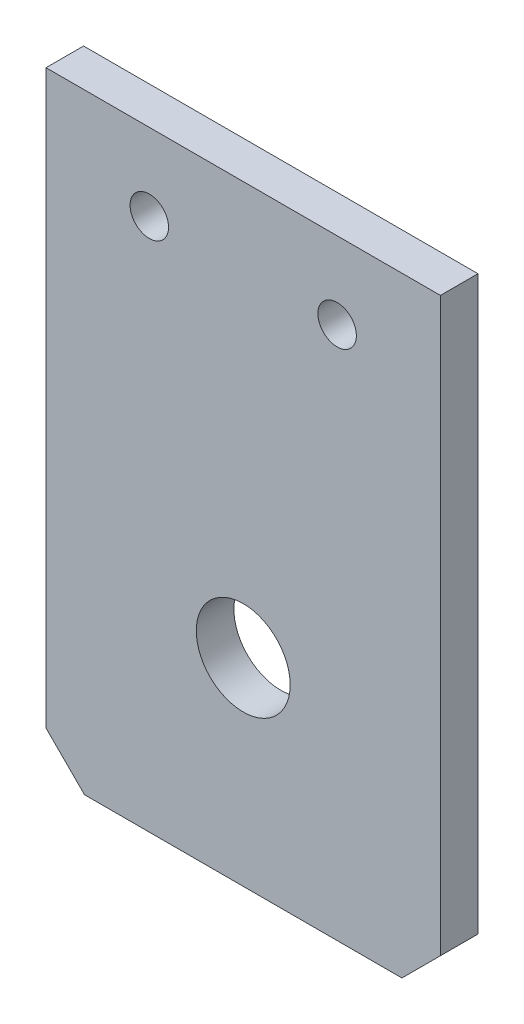
from build123d import *

# Parameters (mm, degrees)
CROQUIS1_W              = 42
CROQUIS1_H              = 65
CROQUIS1_R              = 2.05
SALIENTE_EXTRUIR1_DEPTH = 4
CHAFL_N1_SIZE           = 4.1
CROQUIS5_R              = 5
CORTAR_EXTRUIR2_DEPTH   = 5


with BuildPart() as part:
    # Croquis1 → Saliente-Extruir1 (new body)
    with BuildSketch(Plane.XY):
        with Locations((21, 32.5)):
            Rectangle(CROQUIS1_W, CROQUIS1_H)
        with Locations((11, 56.8)):
            Circle(CROQUIS1_R, mode=Mode.SUBTRACT)
        with Locations((31, 56.8)):
            Circle(CROQUIS1_R, mode=Mode.SUBTRACT)
    extrude(amount=SALIENTE_EXTRUIR1_DEPTH)

    # Chaflán1
    chafl_n1_edges = [part.edges().sort_by_distance(p)[0] for p in [
        (42, 0, 2),
        (0, 0, 2),
    ]]
    chamfer(chafl_n1_edges, length=CHAFL_N1_SIZE)

    # Croquis5 → Cortar-Extruir2 (cut, through all)
    with BuildSketch(Plane.XY.offset(4)):
        with Locations((21, 21.08)):
            Circle(CROQUIS5_R)
    extrude(amount=-CORTAR_EXTRUIR2_DEPTH, mode=Mode.SUBTRACT)


solid = part.part
